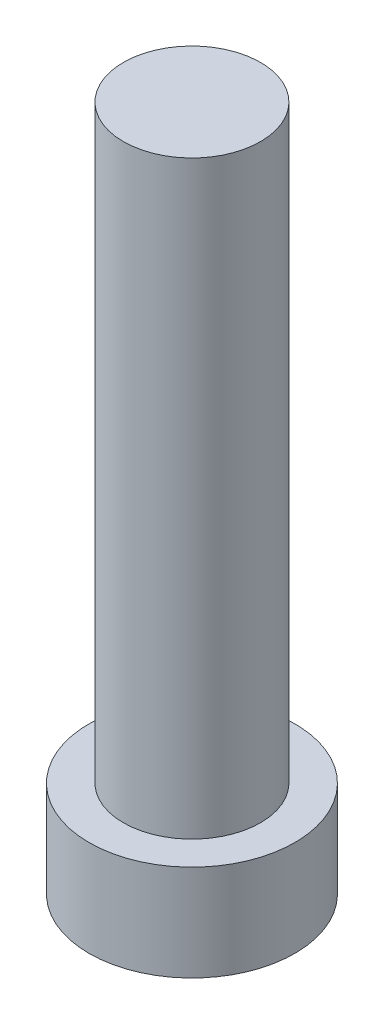
from build123d import *

# Parameters (mm, degrees)
SKETCH1_R           = 7.5
BOSS_EXTRUDE1_DEPTH = 7
SKETCH2_R           = 5
BOSS_EXTRUDE2_DEPTH = 43


with BuildPart() as part:
    # Sketch1 → Boss-Extrude1 (new body)
    with BuildSketch(Plane(origin=(0, 0, 0), x_dir=(1, 0, 0), z_dir=(0, 1, 0))):
        Circle(SKETCH1_R)
    extrude(amount=BOSS_EXTRUDE1_DEPTH)

    # Sketch2 → Boss-Extrude2 (add)
    with BuildSketch(Plane(origin=(0, 7, 0), x_dir=(1, 0, 0), z_dir=(0, 1, 0))):
        Circle(SKETCH2_R)
    extrude(amount=BOSS_EXTRUDE2_DEPTH)


solid = part.part
